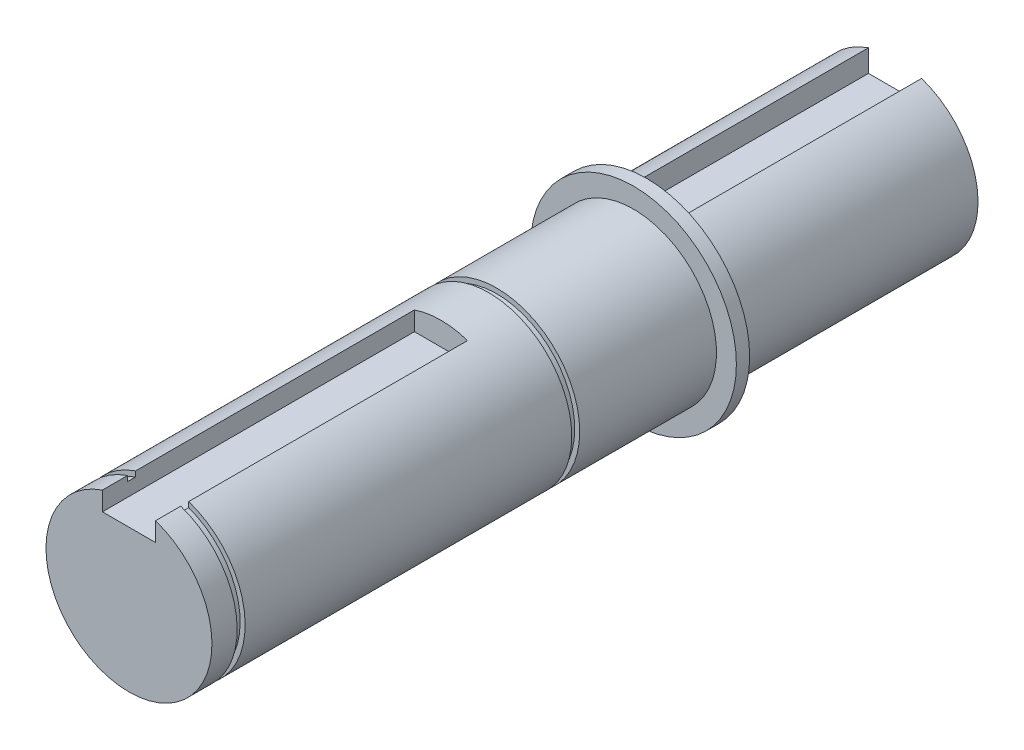
from build123d import *

# Parameters (mm, degrees)
SKETCH1_R           = 12.5
BOSS_EXTRUDE1_DEPTH = 115.4
SKETCH4_W           = 8
SKETCH4_H           = 8
CUT_EXTRUDE1_DEPTH  = 35.4
SKETCH11_R          = 15.5
BOSS_EXTRUDE4_DEPTH = 2
SKETCH12_R          = 12.5
SKETCH12_R_2        = 11.75
CUT_EXTRUDE2_DEPTH  = 1.2
SKETCH13_W          = 8
SKETCH13_H          = 7
CUT_EXTRUDE3_DEPTH  = 47
SKETCH16_R          = 12.5
SKETCH16_R_2        = 11.75
CUT_EXTRUDE5_DEPTH  = 1.2


with BuildPart() as part:
    # Sketch1 → Boss-Extrude1 (new body)
    with BuildSketch(Plane.XY):
        Circle(SKETCH1_R)
    extrude(amount=BOSS_EXTRUDE1_DEPTH)

    # Sketch4 → Cut-Extrude1 (cut)
    with BuildSketch(Plane(origin=(0, 0, 0), x_dir=(-1, 0, 0), z_dir=(0, 0, -1))):
        with Locations((0, 12.5)):
            Rectangle(SKETCH4_W, SKETCH4_H)
    extrude(amount=-CUT_EXTRUDE1_DEPTH, mode=Mode.SUBTRACT)

    # Sketch11 → Boss-Extrude4 (add)
    with BuildSketch(Plane(origin=(0, 0, 37.4), x_dir=(-1, 0, 0), z_dir=(0, 0, -1))):
        Circle(SKETCH11_R)
    extrude(amount=-BOSS_EXTRUDE4_DEPTH)

    # Sketch12 → Cut-Extrude2 (cut)
    with BuildSketch(Plane.XY.offset(60)):
        Circle(SKETCH12_R)
        Circle(SKETCH12_R_2, mode=Mode.SUBTRACT)
    extrude(amount=CUT_EXTRUDE2_DEPTH, mode=Mode.SUBTRACT)

    # Sketch13 → Cut-Extrude3 (cut)
    with BuildSketch(Plane.XY.offset(115.4)):
        with Locations((0, 12.5)):
            Rectangle(SKETCH13_W, SKETCH13_H)
    extrude(amount=-CUT_EXTRUDE3_DEPTH, mode=Mode.SUBTRACT)

    # Sketch16 → Cut-Extrude5 (cut)
    with BuildSketch(Plane.XY.offset(110.4)):
        Circle(SKETCH16_R)
        Circle(SKETCH16_R_2, mode=Mode.SUBTRACT)
    extrude(amount=CUT_EXTRUDE5_DEPTH, mode=Mode.SUBTRACT)


solid = part.part
